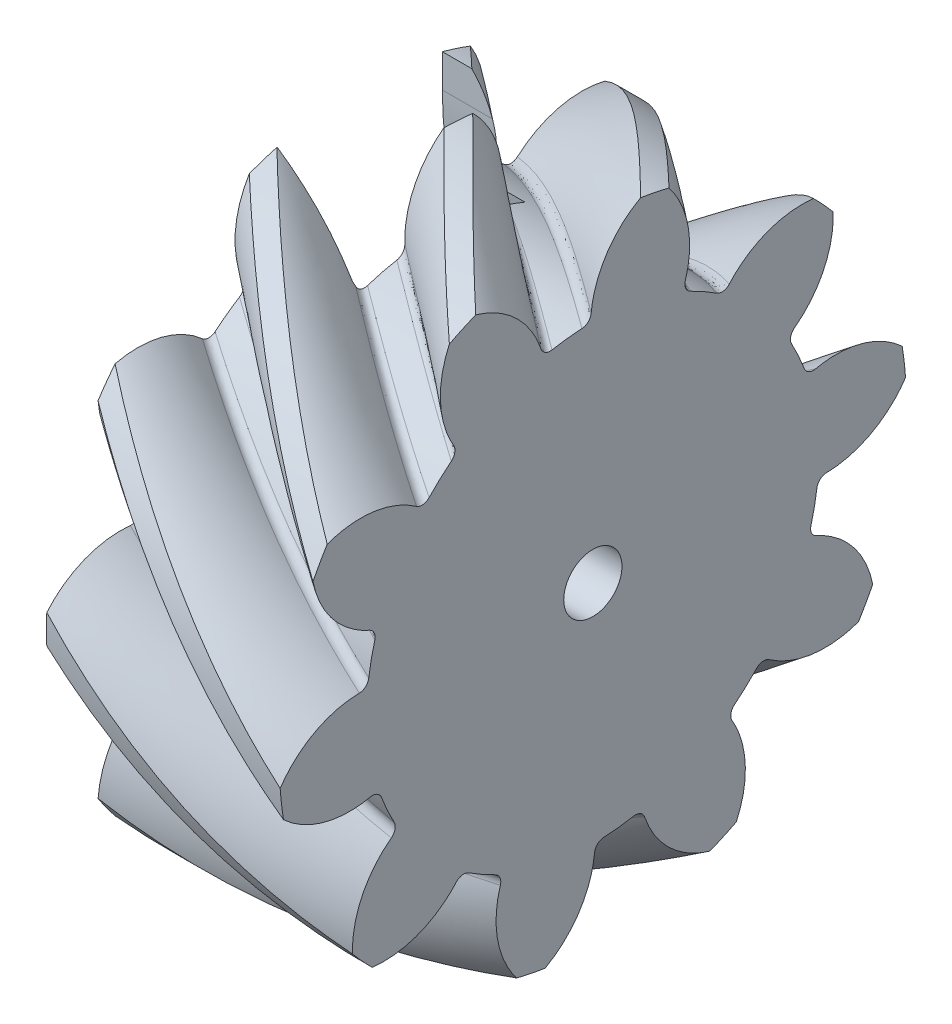
from build123d import *

# Parameters (mm, degrees)
BASPROSKE_W            = 12
BASPROSKE_H            = 16.142135624
TOOTHCUTRH_PITCH       = 101.424029378
TOOTHCUTRH_HEIGHT      = 12
TOOTHCUTRH_RADIUS      = 16.142135624
TOOTHCUTRH_START_ANGLE = -90
TEETHCUTSRH_COUNT      = 10
TEETHCUTSRH_ANGLE      = 324
BORSKE_R               = 1.5
BORE_DEPTH             = 62.5000025
CUT_EXTRUDE2_DEPTH     = 4


with BuildPart() as part:
    # BasProSke → Base-Revolve (revolve)
    with BuildSketch(Plane(origin=(0, 0, 0), x_dir=(1, 0, 0), z_dir=(0, 1, 0))):
        with Locations((6, 8.071067812)):
            Rectangle(BASPROSKE_W, BASPROSKE_H)
    revolve(axis=Axis((-10, 0, 0), (1, 0, 0)))

    # ToothCutRH: sweep along a helix
    with BuildLine() as toothcutrh_path:
        add(Helix(TOOTHCUTRH_PITCH, TOOTHCUTRH_HEIGHT, TOOTHCUTRH_RADIUS, center=(0, 0, 0), direction=(1, 0, 0), mode=Mode.PRIVATE).rotate(Axis((0, 0, 0), (1, 0, 0)), TOOTHCUTRH_START_ANGLE))
    # TooCutSkeRH → ToothCutRH (sweep, cut)
    with BuildSketch(Plane(origin=(0, 0, 0), x_dir=(0, 0, -1), z_dir=(1, 0, 0))):
        with BuildLine():
            ThreePointArc((0.777485713, 11.616145568), (0, 11.642135624), (-0.777485713, 11.616145568))
            ThreePointArc((-0.777485713, 11.616145568), (-1.112111143, 11.715653474), (-1.300501675, 12.009566742))
            ThreePointArc((-1.300501675, 12.009566742), (-2.640329527, 14.472142614), (-5.094931674, 15.826523243))
            ThreePointArc((-5.094931674, 15.826523243), (0, 16.626399692), (5.094931674, 15.826523243))
            ThreePointArc((5.094931674, 15.826523243), (2.640329527, 14.472142614), (1.300501675, 12.009566742))
            ThreePointArc((1.300501675, 12.009566742), (1.112111143, 11.715653474), (0.777485713, 11.616145568))
        make_face()
    toothcutrh = sweep(path=toothcutrh_path.line, is_frenet=True, mode=Mode.SUBTRACT)

    # TeethCutsRH: ToothCutRH ×10 about axis
    teethcutsrh_axis = Axis((-10, 0, 0), (1, 0, 0))
    for i in range(1, TEETHCUTSRH_COUNT):
        add(toothcutrh.rotate(teethcutsrh_axis, i * TEETHCUTSRH_ANGLE / (TEETHCUTSRH_COUNT - 1)), mode=Mode.SUBTRACT)

    # BorSke → Bore (cut, symmetric)
    with BuildSketch(Plane(origin=(0, 0, 0), x_dir=(0, 0, -1), z_dir=(1, 0, 0))):
        Circle(BORSKE_R)
    extrude(amount=BORE_DEPTH, both=True, mode=Mode.SUBTRACT)

    # Sketch4 → Cut-Extrude2 (cut)
    with BuildSketch(Plane(origin=(0, 0, 0), x_dir=(0, 0, -1), z_dir=(1, 0, 0))):
        with BuildLine():
            Line((-4.25, 23.75), (-4.25, 13.863170633))
            ThreePointArc((-4.25, 13.863170633), (-4.926507666, 8.771399196), (-6.909090909, 4.032922366))
            ThreePointArc((-6.909090909, 4.032922366), (0, -8), (6.909090909, 4.032922366))
            ThreePointArc((6.909090909, 4.032922366), (4.926507666, 8.771399196), (4.25, 13.863170633))
            Line((4.25, 13.863170633), (4.25, 23.75))
            ThreePointArc((4.25, 23.75), (0, 28), (-4.25, 23.75))
        make_face()
    extrude(amount=CUT_EXTRUDE2_DEPTH, mode=Mode.SUBTRACT)


solid = part.part
